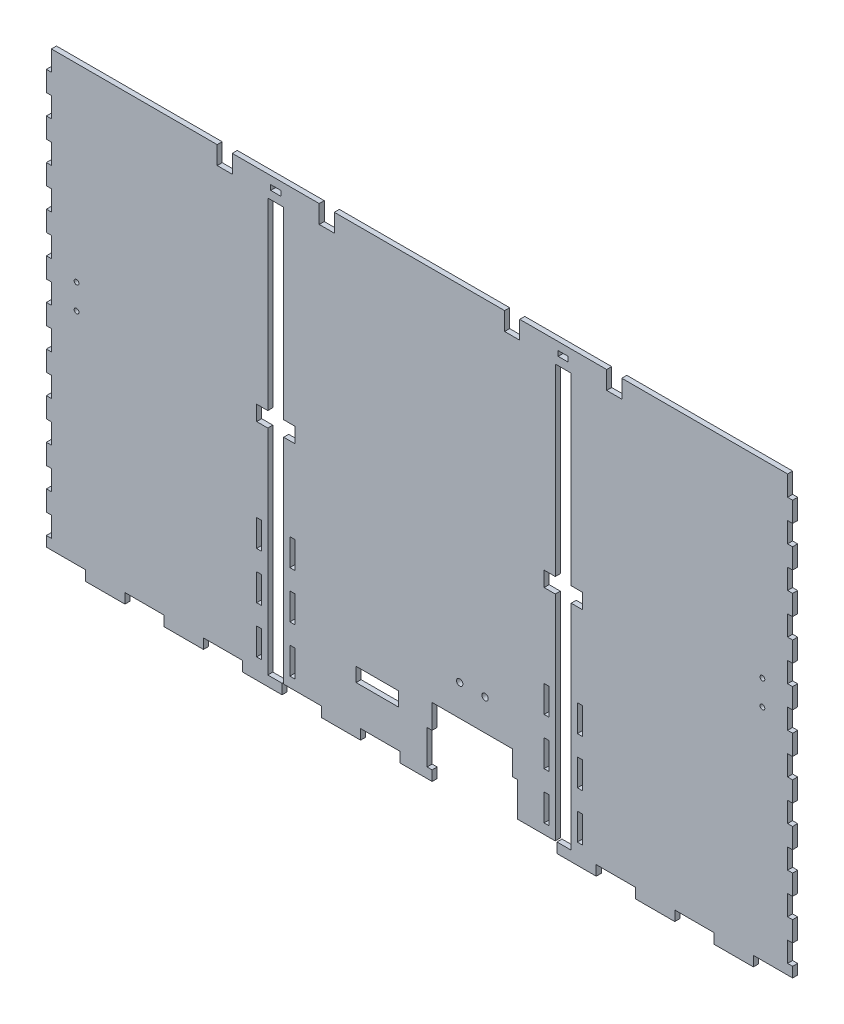
from build123d import *

# Parameters (mm, degrees)
SKETCH1_W                   = 470.789
SKETCH1_H                   = 139.7
BOSS_EXTRUDE1_DEPTH         = 6.35
SKETCH2_W                   = 470.789
SKETCH2_H                   = 139.7
SKETCH2_W_2                 = 464.439
SKETCH2_H_2                 = 133.35
BOSS_EXTRUDE2_DEPTH         = 299.212
SKETCH3_W                   = 10.033
SKETCH3_H                   = 260.604
SKETCH3_W_2                 = 3.175
SKETCH3_H_2                 = 16.933333333
SKETCH3_H_3                 = 16.933333334
SKETCH3_H_4                 = 134.9375
SKETCH3_W_3                 = 7.0485
SKETCH3_H_5                 = 9.525
DOOR_SLOT_DEPTH             = 12.7
LEVERHOLE_CUT_REACH         = 141.7
LEVER_HOLES_R               = 1.5
LEVER_HOLES_W               = 25.4
LEVER_HOLES_H               = 7.62
LEVER_HOLES_W_2             = 4
LEVER_HOLES_H_2             = 6.35
LEVER_HOLES_2_R             = 1.5
LBRACKET_THRU_HOLES_DEPTH   = 140.7
SKETCH8_R                   = 3.175
TETHER_HOLE_DEPTH           = 471.789
DOOR_GUIDE_ROOF_SLOTS_REACH = 141.7
SKETCH16_W                  = 6.35
SKETCH16_H                  = 3.175
SKETCH15_W                  = 136.525
SKETCH15_H                  = 280.162
CUT_EXTRUDE8_DEPTH          = 471.789
FRONT_BACK_W                = 24.778368421
FRONT_BACK_H                = 6.35
FRONT_BACK_W_2              = 3.175
FRONT_BACK_H_2              = 12.734636363
FRONT_BACK_H_3              = 12.734636364
CUT_EXTRUDE9_DEPTH          = 4.175
TROUGH_COVER_HOLES_W        = 50.8
TROUGH_COVER_HOLES_H        = 43.18
TROUGH_COVER_HOLES_W_2      = 3.175
TROUGH_COVER_HOLES_H_2      = 21.59
TROUGH_COVER_HOLES_W_3      = 26.67
TROUGH_COVER_HOLES_H_3      = 8.89
TROUGH_COVER_HOLES_H_4      = 6.35
TROUGH_COVER_CUT_DEPTH      = 4.175
SKETCH17_R                  = 1.999996
CUT_EXTRUDE10_DEPTH         = 4.175


with BuildPart() as part:
    # Sketch1 → Boss-Extrude1 (new body)
    with BuildSketch(Plane(origin=(0, 0, 0), x_dir=(1, 0, 0), z_dir=(0, 1, 0))):
        Rectangle(SKETCH1_W, SKETCH1_H)
    extrude(amount=BOSS_EXTRUDE1_DEPTH)

    # Sketch2 → Boss-Extrude2 (add)
    with BuildSketch(Plane(origin=(0, 6.35, 0), x_dir=(1, 0, 0), z_dir=(0, 1, 0))):
        Rectangle(SKETCH2_W, SKETCH2_H)
        Rectangle(SKETCH2_W_2, SKETCH2_H_2, mode=Mode.SUBTRACT)
    extrude(amount=BOSS_EXTRUDE2_DEPTH)

    # Sketch3 → Door Slot (cut)
    with BuildSketch(Plane.XY.offset(69.85)):
        with Locations((-90.678, 136.652)):
            Rectangle(SKETCH3_W, SKETCH3_H)
        with Locations((90.678, 136.652)):
            Rectangle(SKETCH3_W, SKETCH3_H)
        with Locations((-101.1555, 80.433333334)):
            Rectangle(SKETCH3_W_2, SKETCH3_H_2)
        with Locations((-101.1555, 50.8)):
            Rectangle(SKETCH3_W_2, SKETCH3_H_3)
        with Locations((-101.1555, 21.166666667)):
            Rectangle(SKETCH3_W_2, SKETCH3_H_2)
        with Locations((101.1555, 80.433333334)):
            Rectangle(SKETCH3_W_2, SKETCH3_H_2)
        with Locations((101.1555, 50.8)):
            Rectangle(SKETCH3_W_2, SKETCH3_H_3)
        with Locations((101.1555, 21.166666667)):
            Rectangle(SKETCH3_W_2, SKETCH3_H_2)
        with Locations((80.2005, 50.8)):
            Rectangle(SKETCH3_W_2, SKETCH3_H_3)
        with Locations((80.2005, 21.166666667)):
            Rectangle(SKETCH3_W_2, SKETCH3_H_2)
        with Locations((80.2005, 80.433333334)):
            Rectangle(SKETCH3_W_2, SKETCH3_H_2)
        with Locations((-80.2005, 80.433333334)):
            Rectangle(SKETCH3_W_2, SKETCH3_H_2)
        with Locations((-80.2005, 50.8)):
            Rectangle(SKETCH3_W_2, SKETCH3_H_3)
        with Locations((-80.2005, 21.166666667)):
            Rectangle(SKETCH3_W_2, SKETCH3_H_2)
        with Locations((90.678, 73.81875)):
            Rectangle(SKETCH3_W, SKETCH3_H_4)
        with Locations((82.13725, 146.05)):
            Rectangle(SKETCH3_W_3, SKETCH3_H_5)
        with Locations((99.21875, 146.05)):
            Rectangle(SKETCH3_W_3, SKETCH3_H_5)
        with Locations((-82.13725, 146.05)):
            Rectangle(SKETCH3_W_3, SKETCH3_H_5)
        with Locations((-99.21875, 146.05)):
            Rectangle(SKETCH3_W_3, SKETCH3_H_5)
    extrude(amount=-DOOR_SLOT_DEPTH, mode=Mode.SUBTRACT)

    # Lever Holes → LeverHole Cut (cut, up to next)
    with BuildSketch(Plane.XY.offset(-69.85), mode=Mode.PRIVATE) as leverhole_cut_sk1:
        with Locations((216.3445, 160.655)):
            Circle(LEVER_HOLES_R)
    leverhole_cut_tool1 = extrude(leverhole_cut_sk1.sketch, amount=LEVERHOLE_CUT_REACH, mode=Mode.PRIVATE) & part.part
    add(leverhole_cut_tool1.solids().sort_by_distance((216.3445, 160.655, -69.85))[0], mode=Mode.SUBTRACT)
    # Lever Holes → LeverHole Cut (cut, up to next)
    with BuildSketch(Plane.XY.offset(-69.85), mode=Mode.PRIVATE) as leverhole_cut_sk2:
        with Locations((216.3445, 144.907)):
            Circle(LEVER_HOLES_R)
    leverhole_cut_tool2 = extrude(leverhole_cut_sk2.sketch, amount=LEVERHOLE_CUT_REACH, mode=Mode.PRIVATE) & part.part
    add(leverhole_cut_tool2.solids().sort_by_distance((216.3445, 144.907, -69.85))[0], mode=Mode.SUBTRACT)
    # Lever Holes → LeverHole Cut (cut, up to next)
    with BuildSketch(Plane.XY.offset(-69.85), mode=Mode.PRIVATE) as leverhole_cut_sk3:
        with Locations((-216.3445, 160.655)):
            Circle(LEVER_HOLES_R)
    leverhole_cut_tool3 = extrude(leverhole_cut_sk3.sketch, amount=LEVERHOLE_CUT_REACH, mode=Mode.PRIVATE) & part.part
    add(leverhole_cut_tool3.solids().sort_by_distance((-216.3445, 160.655, -69.85))[0], mode=Mode.SUBTRACT)
    # Lever Holes → LeverHole Cut (cut, up to next)
    with BuildSketch(Plane.XY.offset(-69.85), mode=Mode.PRIVATE) as leverhole_cut_sk4:
        with Locations((-216.3445, 144.907)):
            Circle(LEVER_HOLES_R)
    leverhole_cut_tool4 = extrude(leverhole_cut_sk4.sketch, amount=LEVERHOLE_CUT_REACH, mode=Mode.PRIVATE) & part.part
    add(leverhole_cut_tool4.solids().sort_by_distance((-216.3445, 144.907, -69.85))[0], mode=Mode.SUBTRACT)
    # Lever Holes → LeverHole Cut (cut, up to next)
    with BuildSketch(Plane.XY.offset(-69.85), mode=Mode.PRIVATE) as leverhole_cut_sk5:
        with Locations((-54.4739946, 33.8749894)):
            Rectangle(LEVER_HOLES_W, LEVER_HOLES_H)
    leverhole_cut_tool5 = extrude(leverhole_cut_sk5.sketch, amount=LEVERHOLE_CUT_REACH, mode=Mode.PRIVATE) & part.part
    add(leverhole_cut_tool5.solids().sort_by_distance((-54.473995, 33.874989, -69.85))[0], mode=Mode.SUBTRACT)
    # Lever Holes → LeverHole Cut (cut, up to next)
    with BuildSketch(Plane.XY.offset(-69.85), mode=Mode.PRIVATE) as leverhole_cut_sk6:
        with Locations((-65.7239946, 13.175)):
            Rectangle(LEVER_HOLES_W_2, LEVER_HOLES_H_2)
    leverhole_cut_tool6 = extrude(leverhole_cut_sk6.sketch, amount=LEVERHOLE_CUT_REACH, mode=Mode.PRIVATE) & part.part
    add(leverhole_cut_tool6.solids().sort_by_distance((-65.723995, 13.175, -69.85))[0], mode=Mode.SUBTRACT)
    # Lever Holes → LeverHole Cut (cut, up to next)
    with BuildSketch(Plane.XY.offset(-69.85), mode=Mode.PRIVATE) as leverhole_cut_sk7:
        with Locations((-19.7240014, 13.175)):
            Rectangle(LEVER_HOLES_W_2, LEVER_HOLES_H_2)
    leverhole_cut_tool7 = extrude(leverhole_cut_sk7.sketch, amount=LEVERHOLE_CUT_REACH, mode=Mode.PRIVATE) & part.part
    add(leverhole_cut_tool7.solids().sort_by_distance((-19.724001, 13.175, -69.85))[0], mode=Mode.SUBTRACT)
    # Lever Holes → LeverHole Cut (cut, up to next)
    with BuildSketch(Plane.XY.offset(-69.85), mode=Mode.PRIVATE) as leverhole_cut_sk8:
        with Locations((19.7240014, 13.175)):
            Rectangle(LEVER_HOLES_W_2, LEVER_HOLES_H_2)
    leverhole_cut_tool8 = extrude(leverhole_cut_sk8.sketch, amount=LEVERHOLE_CUT_REACH, mode=Mode.PRIVATE) & part.part
    add(leverhole_cut_tool8.solids().sort_by_distance((19.724001, 13.175, -69.85))[0], mode=Mode.SUBTRACT)
    # Lever Holes → LeverHole Cut (cut, up to next)
    with BuildSketch(Plane.XY.offset(-69.85), mode=Mode.PRIVATE) as leverhole_cut_sk9:
        with Locations((54.4739946, 33.8749894)):
            Rectangle(LEVER_HOLES_W, LEVER_HOLES_H)
    leverhole_cut_tool9 = extrude(leverhole_cut_sk9.sketch, amount=LEVERHOLE_CUT_REACH, mode=Mode.PRIVATE) & part.part
    add(leverhole_cut_tool9.solids().sort_by_distance((54.473995, 33.874989, -69.85))[0], mode=Mode.SUBTRACT)
    # Lever Holes → LeverHole Cut (cut, up to next)
    with BuildSketch(Plane.XY.offset(-69.85), mode=Mode.PRIVATE) as leverhole_cut_sk10:
        with Locations((65.7239946, 13.175)):
            Rectangle(LEVER_HOLES_W_2, LEVER_HOLES_H_2)
    leverhole_cut_tool10 = extrude(leverhole_cut_sk10.sketch, amount=LEVERHOLE_CUT_REACH, mode=Mode.PRIVATE) & part.part
    add(leverhole_cut_tool10.solids().sort_by_distance((65.723995, 13.175, -69.85))[0], mode=Mode.SUBTRACT)

    # Lever Holes_2 → Lbracket Thru Holes (cut, through all)
    with BuildSketch(Plane.XY.offset(-69.85)):
        with Locations((216.3445, 160.655)):
            Circle(LEVER_HOLES_2_R)
        with Locations((216.3445, 144.907)):
            Circle(LEVER_HOLES_2_R)
        with Locations((-216.3445, 160.655)):
            Circle(LEVER_HOLES_2_R)
        with Locations((-216.3445, 144.907)):
            Circle(LEVER_HOLES_2_R)
    extrude(amount=LBRACKET_THRU_HOLES_DEPTH, mode=Mode.SUBTRACT)

    # Sketch8 → Tether Hole (cut, through all)
    with BuildSketch(Plane.ZY.offset(235.3945)):
        with Locations((0, 11.43)):
            Circle(SKETCH8_R)
    extrude(amount=-TETHER_HOLE_DEPTH, mode=Mode.SUBTRACT)

    # Sketch16 → Door Guide Roof Slots (cut, up to next)
    with BuildSketch(Plane.XY.offset(69.85), mode=Mode.PRIVATE) as door_guide_roof_slots_sk1:
        Polygon((53.721, 280.162), (53.721, 268.732), (63.246, 268.732), (63.246, 280.162), (118.11, 280.162), (118.11, 268.732), (127.635, 268.732), (127.635, 280.162), (235.3945, 280.162), (235.3945, 305.562), (-235.3945, 305.562), (-235.3945, 280.162), (-127.635, 280.162), (-127.635, 268.732), (-118.11, 268.732), (-118.11, 280.162), (-63.246, 280.162), (-63.246, 268.732), (-53.721, 268.732), (-53.721, 280.162), align=None)
    door_guide_roof_slots_tool1 = extrude(door_guide_roof_slots_sk1.sketch, amount=-DOOR_GUIDE_ROOF_SLOTS_REACH, mode=Mode.PRIVATE) & part.part
    add(door_guide_roof_slots_tool1.solids().sort_by_distance((0, 292.214935, 69.85))[0], mode=Mode.SUBTRACT)
    # Sketch16 → Door Guide Roof Slots (cut, up to next)
    with BuildSketch(Plane.XY.offset(69.85), mode=Mode.PRIVATE) as door_guide_roof_slots_sk2:
        with Locations((90.678, 273.6215)):
            Rectangle(SKETCH16_W, SKETCH16_H)
    door_guide_roof_slots_tool2 = extrude(door_guide_roof_slots_sk2.sketch, amount=-DOOR_GUIDE_ROOF_SLOTS_REACH, mode=Mode.PRIVATE) & part.part
    add(door_guide_roof_slots_tool2.solids().sort_by_distance((90.678, 273.6215, 69.85))[0], mode=Mode.SUBTRACT)
    # Sketch16 → Door Guide Roof Slots (cut, up to next)
    with BuildSketch(Plane.XY.offset(69.85), mode=Mode.PRIVATE) as door_guide_roof_slots_sk3:
        with Locations((-90.678, 273.6215)):
            Rectangle(SKETCH16_W, SKETCH16_H)
    door_guide_roof_slots_tool3 = extrude(door_guide_roof_slots_sk3.sketch, amount=-DOOR_GUIDE_ROOF_SLOTS_REACH, mode=Mode.PRIVATE) & part.part
    add(door_guide_roof_slots_tool3.solids().sort_by_distance((-90.678, 273.6215, 69.85))[0], mode=Mode.SUBTRACT)

    # Sketch15 → Cut-Extrude8 (cut, through all)
    with BuildSketch(Plane.ZY.offset(235.3945)):
        with Locations((-1.5875, 140.081)):
            Rectangle(SKETCH15_W, SKETCH15_H)
    extrude(amount=-CUT_EXTRUDE8_DEPTH, mode=Mode.SUBTRACT)

    # Front_Back → Cut-Extrude9 (cut, through all)
    with BuildSketch(Plane.XY.offset(69.85)):
        with Locations((-223.00531579, 3.175)):
            Rectangle(FRONT_BACK_W, FRONT_BACK_H)
        with Locations((-233.807, 19.101954545)):
            Rectangle(FRONT_BACK_W_2, FRONT_BACK_H_2)
        with Locations((-173.448578948, 3.175)):
            Rectangle(FRONT_BACK_W, FRONT_BACK_H)
        with Locations((-233.807, 44.571227273)):
            Rectangle(FRONT_BACK_W_2, FRONT_BACK_H_3)
        with Locations((-123.891842106, 3.175)):
            Rectangle(FRONT_BACK_W, FRONT_BACK_H)
        with Locations((-233.807, 70.0405)):
            Rectangle(FRONT_BACK_W_2, FRONT_BACK_H_3)
        with Locations((-74.335105263, 3.175)):
            Rectangle(FRONT_BACK_W, FRONT_BACK_H)
        with Locations((-233.807, 95.509772727)):
            Rectangle(FRONT_BACK_W_2, FRONT_BACK_H_3)
        with Locations((-24.778368422, 3.175)):
            Rectangle(FRONT_BACK_W, FRONT_BACK_H)
        with Locations((-233.807, 120.979045455)):
            Rectangle(FRONT_BACK_W_2, FRONT_BACK_H_2)
        with Locations((24.778368422, 3.175)):
            Rectangle(FRONT_BACK_W, FRONT_BACK_H)
        with Locations((-233.807, 146.448318182)):
            Rectangle(FRONT_BACK_W_2, FRONT_BACK_H_3)
        with Locations((74.335105263, 3.175)):
            Rectangle(FRONT_BACK_W, FRONT_BACK_H)
        with Locations((-233.807, 171.917590909)):
            Rectangle(FRONT_BACK_W_2, FRONT_BACK_H_3)
        with Locations((123.891842106, 3.175)):
            Rectangle(FRONT_BACK_W, FRONT_BACK_H)
        with Locations((-233.807, 197.386863637)):
            Rectangle(FRONT_BACK_W_2, FRONT_BACK_H_2)
        with Locations((173.448578948, 3.175)):
            Rectangle(FRONT_BACK_W, FRONT_BACK_H)
        with Locations((-233.807, 222.856136364)):
            Rectangle(FRONT_BACK_W_2, FRONT_BACK_H_2)
        with Locations((223.00531579, 3.175)):
            Rectangle(FRONT_BACK_W, FRONT_BACK_H)
        with Locations((-233.807, 248.325409091)):
            Rectangle(FRONT_BACK_W_2, FRONT_BACK_H_3)
        with Locations((233.807, 19.101954545)):
            Rectangle(FRONT_BACK_W_2, FRONT_BACK_H_2)
        with Locations((-233.807, 273.794681818)):
            Rectangle(FRONT_BACK_W_2, FRONT_BACK_H_3)
        with Locations((233.807, 44.571227273)):
            Rectangle(FRONT_BACK_W_2, FRONT_BACK_H_3)
        with Locations((233.807, 70.0405)):
            Rectangle(FRONT_BACK_W_2, FRONT_BACK_H_3)
        with Locations((233.807, 95.509772727)):
            Rectangle(FRONT_BACK_W_2, FRONT_BACK_H_3)
        with Locations((233.807, 120.979045455)):
            Rectangle(FRONT_BACK_W_2, FRONT_BACK_H_2)
        with Locations((233.807, 146.448318182)):
            Rectangle(FRONT_BACK_W_2, FRONT_BACK_H_3)
        with Locations((233.807, 171.917590909)):
            Rectangle(FRONT_BACK_W_2, FRONT_BACK_H_3)
        with Locations((233.807, 197.386863637)):
            Rectangle(FRONT_BACK_W_2, FRONT_BACK_H_2)
        with Locations((233.807, 222.856136364)):
            Rectangle(FRONT_BACK_W_2, FRONT_BACK_H_2)
        with Locations((233.807, 248.325409091)):
            Rectangle(FRONT_BACK_W_2, FRONT_BACK_H_3)
        with Locations((233.807, 273.794681818)):
            Rectangle(FRONT_BACK_W_2, FRONT_BACK_H_3)
    extrude(amount=-CUT_EXTRUDE9_DEPTH, mode=Mode.SUBTRACT)

    # Trough Cover Holes → Trough Cover Cut (cut, through all)
    with BuildSketch(Plane(origin=(0, 0, 66.675), x_dir=(-1, 0, 0), z_dir=(0, 0, -1))):
        with Locations((-33.370921053, 21.59)):
            Rectangle(TROUGH_COVER_HOLES_W, TROUGH_COVER_HOLES_H)
        with Locations((-60.358421053, 17.145)):
            Rectangle(TROUGH_COVER_HOLES_W_2, TROUGH_COVER_HOLES_H_2)
        with Locations((-6.383421053, 17.145)):
            Rectangle(TROUGH_COVER_HOLES_W_2, TROUGH_COVER_HOLES_H_2)
        with Locations((26.69920025, 34.5099894)):
            Rectangle(TROUGH_COVER_HOLES_W_3, TROUGH_COVER_HOLES_H_3)
        with Locations((-60.358421053, 3.175)):
            Rectangle(TROUGH_COVER_HOLES_W_2, TROUGH_COVER_HOLES_H_4)
    extrude(amount=-TROUGH_COVER_CUT_DEPTH, mode=Mode.SUBTRACT)

    # Sketch17 → Cut-Extrude10 (cut, through all)
    with BuildSketch(Plane(origin=(0, 0, 66.675), x_dir=(-1, 0, 0), z_dir=(0, 0, -1))):
        with Locations((-41.370651053, 62.84976)):
            Circle(SKETCH17_R)
        with Locations((-25.371191053, 62.84976)):
            Circle(SKETCH17_R)
    extrude(amount=-CUT_EXTRUDE10_DEPTH, mode=Mode.SUBTRACT)


solid = part.part
